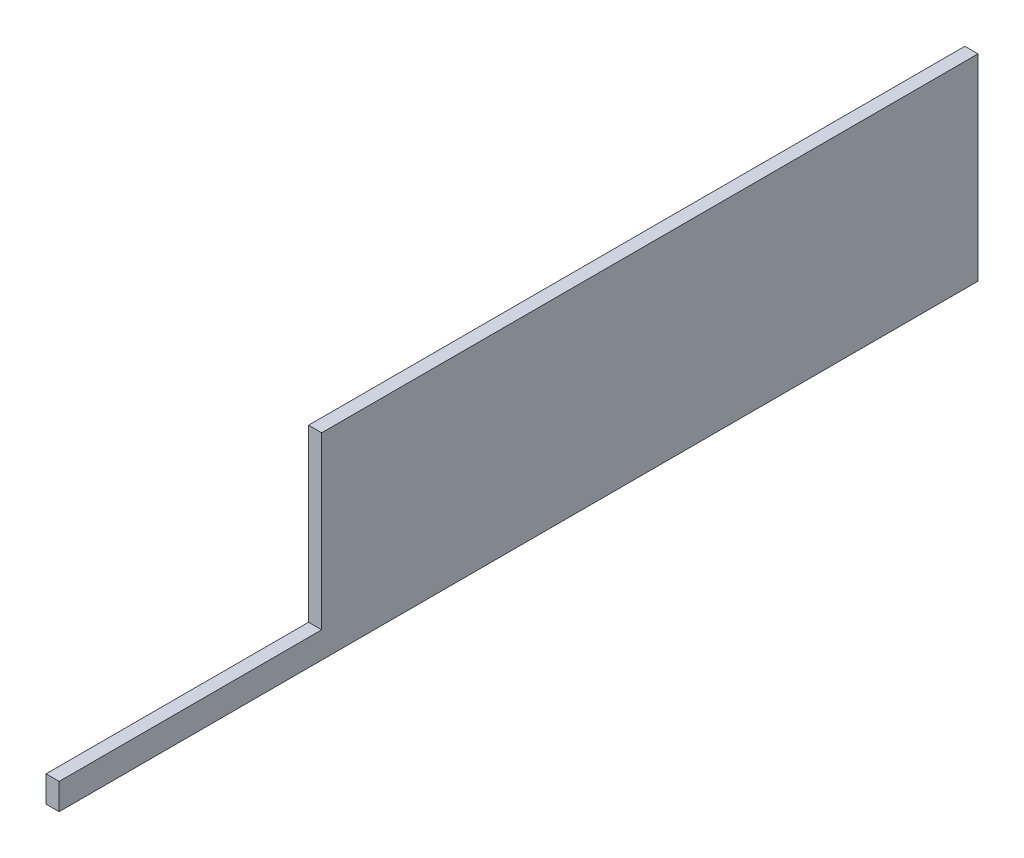
from build123d import *

# Parameters (mm, degrees)
CROQUIS1_W              = 20
CROQUIS1_H              = 2
CROQUIS1_W_2            = 50
CROQUIS1_H_2            = 15
SALIENTE_EXTRUIR1_DEPTH = 1


with BuildPart() as part:
    # Croquis1 → Saliente-Extruir1 (new body)
    with BuildSketch(Plane(origin=(0, 0, 0), x_dir=(0, 0, -1), z_dir=(1, 0, 0))):
        with Locations((-35, -6.5)):
            Rectangle(CROQUIS1_W, CROQUIS1_H)
        Rectangle(CROQUIS1_W_2, CROQUIS1_H_2)
    extrude(amount=SALIENTE_EXTRUIR1_DEPTH)


solid = part.part
